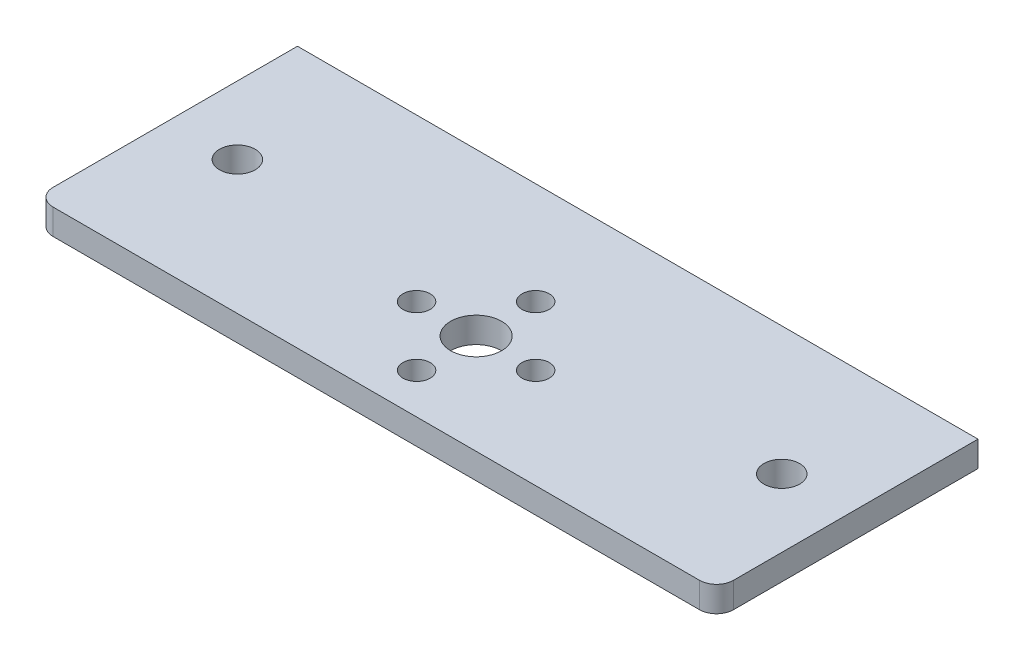
from build123d import *

# Parameters (mm, degrees)
SKETCH1_W           = 80
SKETCH1_H           = 30.74
SKETCH1_R           = 3
SKETCH1_R_2         = 1.6
BOSS_EXTRUDE1_DEPTH = 3
SKETCH2_R           = 2.1
CUT_EXTRUDE1_DEPTH  = 10
FILLET1_R           = 2


with BuildPart() as part:
    # Sketch1 → Boss-Extrude1 (new body)
    with BuildSketch(Plane(origin=(0, 0, 0), x_dir=(1, 0, 0), z_dir=(0, 1, 0))):
        with Locations((0, 3.63)):
            Rectangle(SKETCH1_W, SKETCH1_H)
        Circle(SKETCH1_R, mode=Mode.SUBTRACT)
        with Locations((0, 7)):
            Circle(SKETCH1_R_2, mode=Mode.SUBTRACT)
        with Locations((-7, 0)):
            Circle(SKETCH1_R_2, mode=Mode.SUBTRACT)
        with Locations((0, -7)):
            Circle(SKETCH1_R_2, mode=Mode.SUBTRACT)
        with Locations((7, 0)):
            Circle(SKETCH1_R_2, mode=Mode.SUBTRACT)
    extrude(amount=-BOSS_EXTRUDE1_DEPTH)

    # Sketch2 → Cut-Extrude1 (cut)
    with BuildSketch(Plane(origin=(0, 0, 0), x_dir=(1, 0, 0), z_dir=(0, 1, 0))):
        with Locations((31.999, 3.93)):
            Circle(SKETCH2_R)
        with Locations((-31.999, 3.93)):
            Circle(SKETCH2_R)
    extrude(amount=-CUT_EXTRUDE1_DEPTH, mode=Mode.SUBTRACT)

    # Fillet1
    fillet1_edges = [part.edges().sort_by_distance(p)[0] for p in [
        (40, -1.5, 11.74),
        (-40, -1.5, 11.74),
    ]]
    fillet(fillet1_edges, radius=FILLET1_R)


solid = part.part
